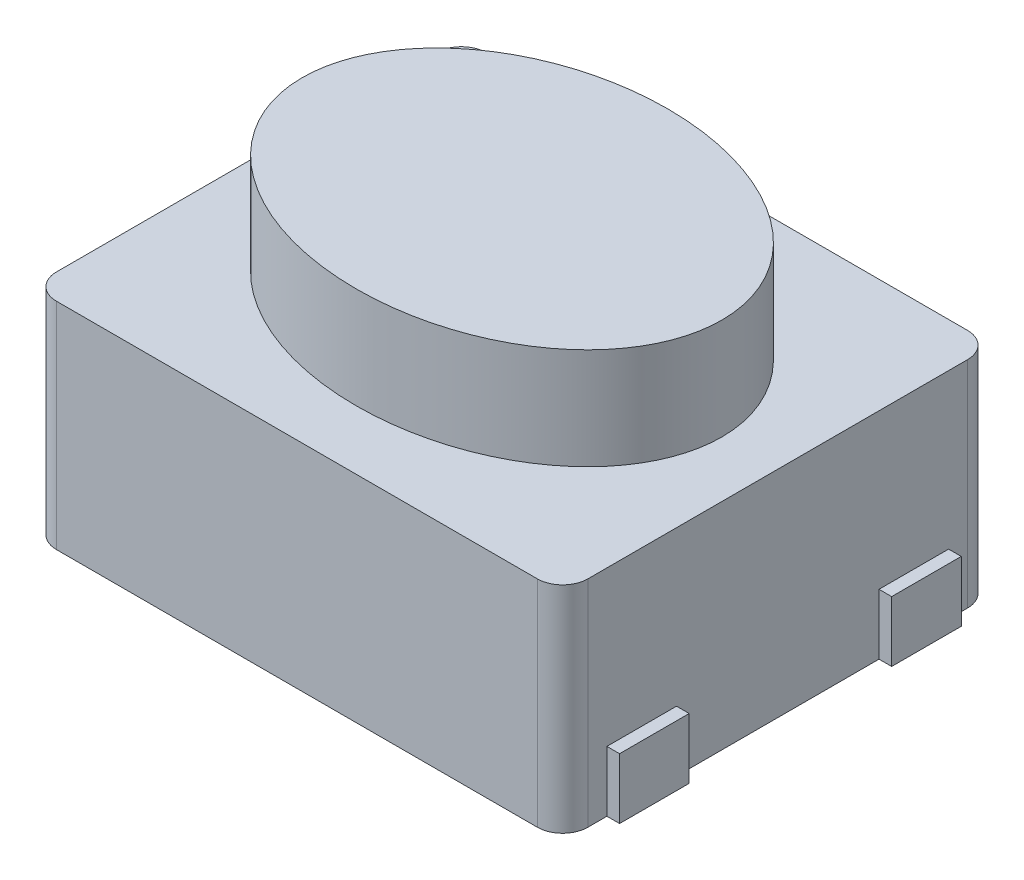
from build123d import *

# Parameters (mm, degrees)
SKETCH_1_W      = 4.2
SKETCH_1_H      = 3.4
EXTRUDE_1_DEPTH = 1.7
SKETCH_2_RX     = 1.658686792
SKETCH_2_RY     = 1.231698113
EXTRUDE_2_DEPTH = 0.8
FILLET_1_R      = 0.2
SKETCH_3_W      = 0.55
SKETCH_3_H      = 0.478335134
EXTRUDE_3_DEPTH = 0.1


with BuildPart() as part:
    # 草图1 → 凸台-拉伸1 (new body)
    with BuildSketch(Plane(origin=(0, 0, 0), x_dir=(1, 0, 0), z_dir=(0, 1, 0))):
        Rectangle(SKETCH_1_W, SKETCH_1_H)
    extrude(amount=EXTRUDE_1_DEPTH)

    # 草图2 → 凸台-拉伸2 (add)
    with BuildSketch(Plane(origin=(0, 1.7, 0), x_dir=(1, 0, 0), z_dir=(0, 1, 0))):
        with Locations((0, 0)):
            Ellipse(SKETCH_2_RX, SKETCH_2_RY)
    extrude(amount=EXTRUDE_2_DEPTH)

    # 圆角1
    fillet_1_edges = [part.edges().sort_by_distance(p)[0] for p in [
        (2.1, 0.85, 1.7),
        (-2.1, 0.85, 1.7),
        (-2.1, 0.85, -1.7),
        (2.1, 0.85, -1.7),
    ]]
    fillet(fillet_1_edges, radius=FILLET_1_R)

    # 草图3 → 凸台-拉伸3 (add)
    with BuildSketch(Plane.ZY.offset(2.1)):
        with Locations((-1.075, 0.239167567)):
            Rectangle(SKETCH_3_W, SKETCH_3_H)
        with Locations((1.075, 0.239167567)):
            Rectangle(SKETCH_3_W, SKETCH_3_H)
    extrude_3 = extrude(amount=EXTRUDE_3_DEPTH)

    # 镜向1: 凸台-拉伸3 across plane
    add(extrude_3.mirror(Plane(origin=(0, 0, 0), x_dir=(0, 0, 1), z_dir=(1, 0, 0))))


solid = part.part
